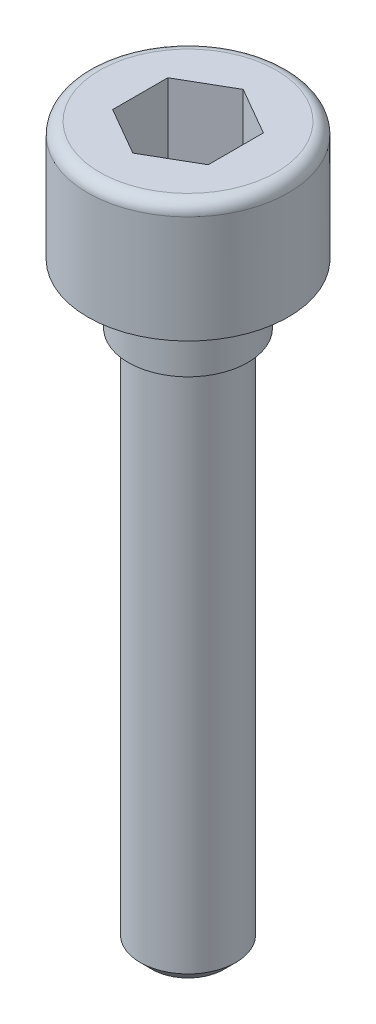
from build123d import *

# Parameters (mm, degrees)
CORTAR_EXTRUIR1_DEPTH = 3
CHAFL_N1_SIZE         = 0.5
REDONDEO1_R           = 0.5
CROQUIS3_W            = 0.5
CROQUIS3_H            = 22.5
CHAFL_N2_SIZE         = 0.5


with BuildPart() as part:
    # Croquis1 → Revolución1 (revolve)
    with BuildSketch(Plane.XY):
        Polygon((0, 0), (4.2, 0), (4.2, -5), (2.5, -5), (2.5, -30), (0, -30), align=None)
    revolve(axis=Axis((0, 0, 0), (0, -1, 0)))

    # Croquis2 → Cortar-Extruir1 (cut)
    with BuildSketch(Plane(origin=(0, 0, 0), x_dir=(1, 0, 0), z_dir=(0, 1, 0))):
        Polygon((2, 1.154700538), (0, 2.309401077), (-2, 1.154700538), (-2, -1.154700538), (0, -2.309401077), (2, -1.154700538), align=None)
    extrude(amount=-CORTAR_EXTRUIR1_DEPTH, mode=Mode.SUBTRACT)

    # Chaflán1
    chafl_n1_edges = [part.edges().sort_by_distance(p)[0] for p in [
        (-2.5, -30, 0),
    ]]
    chamfer(chafl_n1_edges, length=CHAFL_N1_SIZE)

    # Redondeo1
    redondeo1_edges = [part.edges().sort_by_distance(p)[0] for p in [
        (-4.2, 0, 0),
    ]]
    fillet(redondeo1_edges, radius=REDONDEO1_R)

    # Croquis3 → Cortar-Revolución1 (revolve, cut)
    with BuildSketch(Plane.XY):
        with Locations((2.25, -18.75)):
            Rectangle(CROQUIS3_W, CROQUIS3_H)
    revolve(axis=Axis((0, 0, 0), (0, -1, 0)), mode=Mode.SUBTRACT)

    # Chaflán2
    chafl_n2_edges = [part.edges().sort_by_distance(p)[0] for p in [
        (-2, -30, 0),
    ]]
    chamfer(chafl_n2_edges, length=CHAFL_N2_SIZE)


solid = part.part
